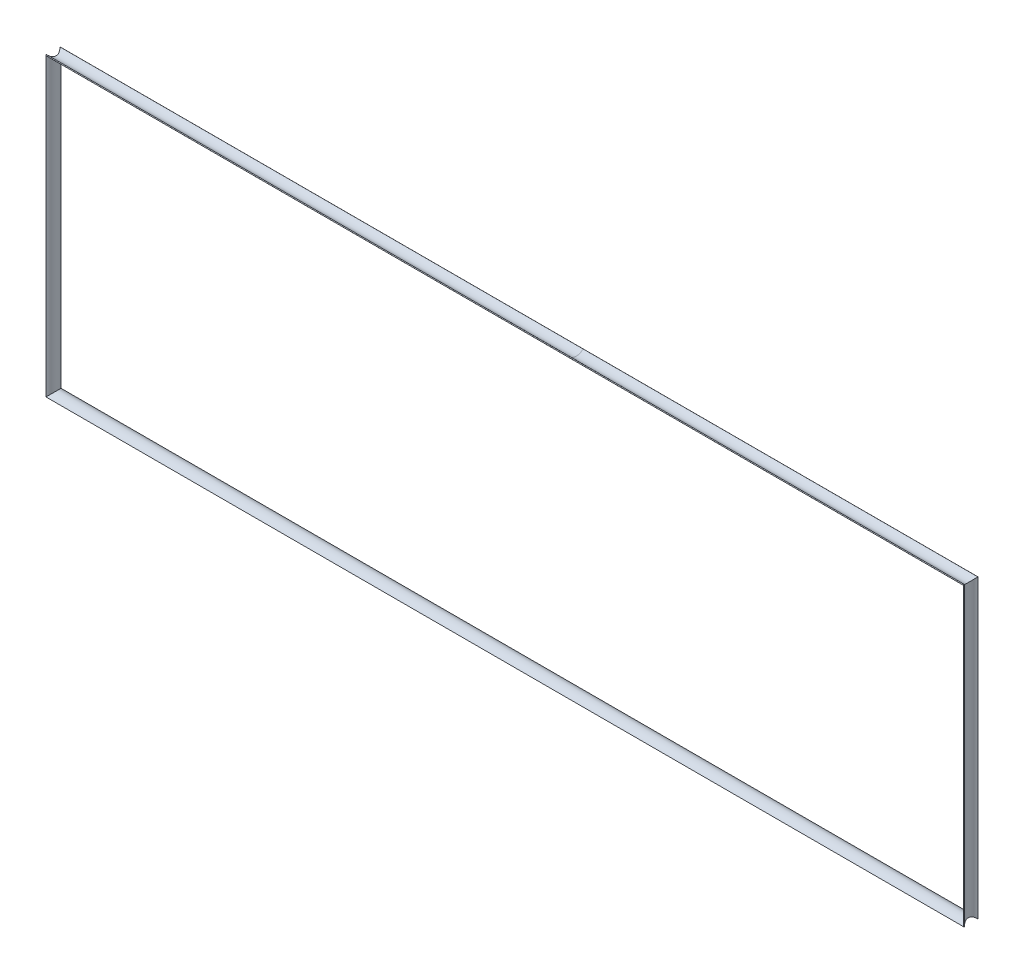
from build123d import *


with BuildPart() as part:
    # Sweep1: sweep along a path in Sketch6
    with BuildLine(Plane.XY) as sweep1_path:
        Line((-194.933333333, 26.876190476), (-194.933333333, -83.123809524))
        Line((-194.933333333, -83.123809524), (147.066666667, -83.123809524))
        Line((147.066666667, -83.123809524), (147.066666667, 26.876190476))
        Line((147.066666667, 26.876190476), (-194.933333333, 26.876190476))
    # Sketch7 → Sweep1 (sweep)
    with BuildSketch(Plane(origin=(0, 0, 0), x_dir=(0, 0, -1), z_dir=(1, 0, 0))):
        with BuildLine():
            Line((2.727993364, 26.945293334), (2.497196154, 27.154925683))
            ThreePointArc((2.497196154, 27.154925683), (-0.045784316, 26.049902517), (-2.557836818, 27.223537083))
            Line((-2.557836818, 27.223537083), (-2.798892732, 27.025668774))
            ThreePointArc((-2.798892732, 27.025668774), (-0.053588552, 25.738191345), (2.727993364, 26.945293334))
        make_face()
    sweep(path=sweep1_path.line, transition=Transition.RIGHT)


solid = part.part
